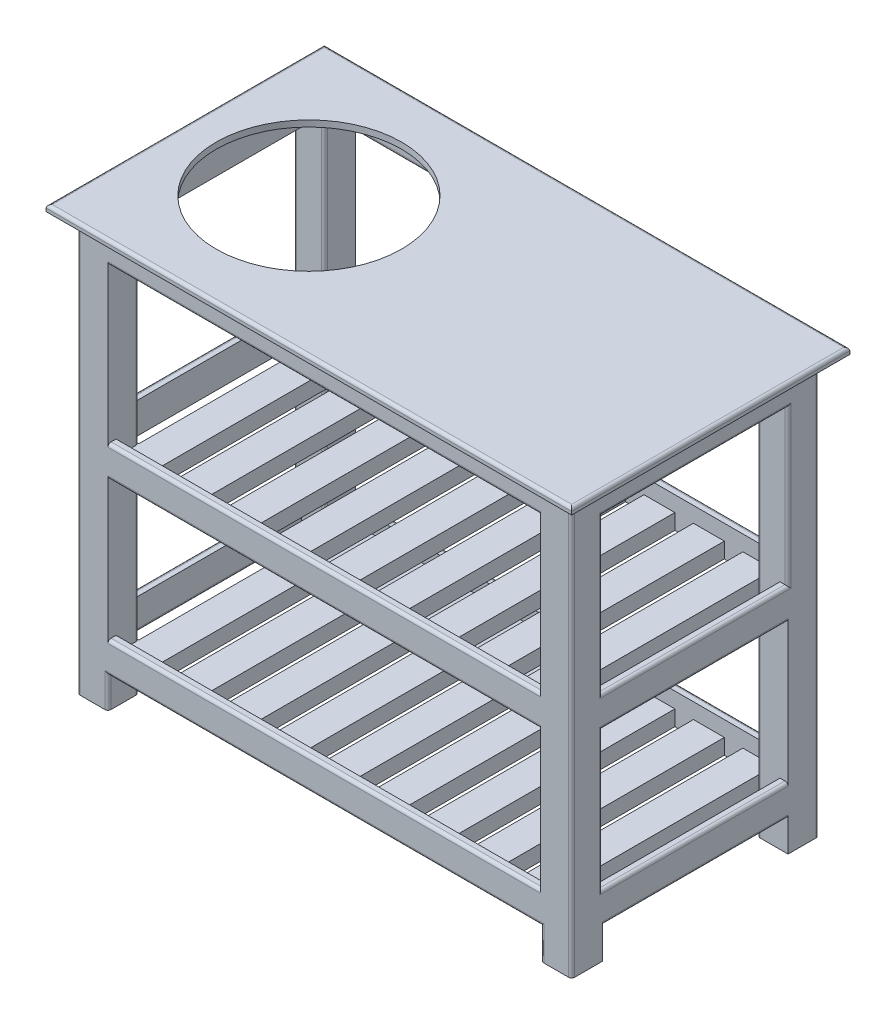
from build123d import *

# Parameters (mm, degrees)
SKETCH1_W           = 850
SKETCH1_H           = 450
BOSS_EXTRUDE1_DEPTH = 10
SKETCH2_W           = 50
SKETCH2_H           = 50
BOSS_EXTRUDE2_DEPTH = 675
BOSS_EXTRUDE3_REACH = 777
SKETCH3_W           = 13
SKETCH3_H           = 50
BOSS_EXTRUDE4_REACH = 377
SKETCH4_W           = 13
SKETCH4_H           = 50
SKETCH5_W           = 50
SKETCH5_H           = 25
BOSS_EXTRUDE5_DEPTH = 374
SKETCH6_W           = 50
SKETCH6_H           = 25
BOSS_EXTRUDE6_DEPTH = 374
LPATTERN2_COUNT     = 9
LPATTERN2_PITCH     = 80
LPATTERN3_COUNT     = 9
LPATTERN3_PITCH     = 80
CUT_EXTRUDE1_REACH  = 687
SKETCH7_R           = 150
FILLET2_R           = 5
FILLET3_R           = 5


with BuildPart() as part:
    # Sketch1 → Boss-Extrude1 (new body)
    with BuildSketch(Plane(origin=(0, 0, 0), x_dir=(1, 0, 0), z_dir=(0, 1, 0))):
        Rectangle(SKETCH1_W, SKETCH1_H)
    extrude(amount=BOSS_EXTRUDE1_DEPTH)

    # Sketch2 → Boss-Extrude2 (add)
    with BuildSketch(Plane.XZ):
        with Locations((-375, -175)):
            Rectangle(SKETCH2_W, SKETCH2_H)
        with Locations((-375, 175)):
            Rectangle(SKETCH2_W, SKETCH2_H)
        with Locations((375, 175)):
            Rectangle(SKETCH2_W, SKETCH2_H)
        with Locations((375, -175)):
            Rectangle(SKETCH2_W, SKETCH2_H)
    extrude(amount=BOSS_EXTRUDE2_DEPTH)

    # Sketch3 → Boss-Extrude3 (add, up to next)
    with BuildSketch(Plane(origin=(-350, 0, 0), x_dir=(0, 0, -1), z_dir=(1, 0, 0)), mode=Mode.PRIVATE) as boss_extrude3_sk1:
        with Locations((193.5, -600)):
            Rectangle(SKETCH3_W, SKETCH3_H)
    boss_extrude3_tool1 = extrude(boss_extrude3_sk1.sketch, amount=BOSS_EXTRUDE3_REACH, mode=Mode.PRIVATE) - part.part
    add(boss_extrude3_tool1.solids().sort_by_distance((-350, -600, -193.5))[0])
    # Sketch3 → Boss-Extrude3 (add, up to next)
    with BuildSketch(Plane(origin=(-350, 0, 0), x_dir=(0, 0, -1), z_dir=(1, 0, 0)), mode=Mode.PRIVATE) as boss_extrude3_sk2:
        with Locations((193.5, -325)):
            Rectangle(SKETCH3_W, SKETCH3_H)
    boss_extrude3_tool2 = extrude(boss_extrude3_sk2.sketch, amount=BOSS_EXTRUDE3_REACH, mode=Mode.PRIVATE) - part.part
    add(boss_extrude3_tool2.solids().sort_by_distance((-350, -325, -193.5))[0])
    # Sketch3 → Boss-Extrude3 (add, up to next)
    with BuildSketch(Plane(origin=(-350, 0, 0), x_dir=(0, 0, -1), z_dir=(1, 0, 0)), mode=Mode.PRIVATE) as boss_extrude3_sk3:
        with Locations((193.5, -25)):
            Rectangle(SKETCH3_W, SKETCH3_H)
    boss_extrude3_tool3 = extrude(boss_extrude3_sk3.sketch, amount=BOSS_EXTRUDE3_REACH, mode=Mode.PRIVATE) - part.part
    add(boss_extrude3_tool3.solids().sort_by_distance((-350, -25, -193.5))[0])

    # Mirror1: part across plane


with BuildPart() as part_1:
    add(part.part)
    add(part.part.mirror(Plane.XY))

    # Sketch4 → Boss-Extrude4 (add, up to next)
    with BuildSketch(Plane.XY.offset(-150), mode=Mode.PRIVATE) as boss_extrude4_sk1:
        with Locations((393.5, -600)):
            Rectangle(SKETCH4_W, SKETCH4_H)
    boss_extrude4_tool1 = extrude(boss_extrude4_sk1.sketch, amount=BOSS_EXTRUDE4_REACH, mode=Mode.PRIVATE) - part_1.part
    add(boss_extrude4_tool1.solids().sort_by_distance((393.5, -600, -150))[0])
    # Sketch4 → Boss-Extrude4 (add, up to next)
    with BuildSketch(Plane.XY.offset(-150), mode=Mode.PRIVATE) as boss_extrude4_sk2:
        with Locations((393.5, -325)):
            Rectangle(SKETCH4_W, SKETCH4_H)
    boss_extrude4_tool2 = extrude(boss_extrude4_sk2.sketch, amount=BOSS_EXTRUDE4_REACH, mode=Mode.PRIVATE) - part_1.part
    add(boss_extrude4_tool2.solids().sort_by_distance((393.5, -325, -150))[0])
    # Sketch4 → Boss-Extrude4 (add, up to next)
    with BuildSketch(Plane.XY.offset(-150), mode=Mode.PRIVATE) as boss_extrude4_sk3:
        with Locations((393.5, -25)):
            Rectangle(SKETCH4_W, SKETCH4_H)
    boss_extrude4_tool3 = extrude(boss_extrude4_sk3.sketch, amount=BOSS_EXTRUDE4_REACH, mode=Mode.PRIVATE) - part_1.part
    add(boss_extrude4_tool3.solids().sort_by_distance((393.5, -25, -150))[0])

    # Mirror2: part across plane


with BuildPart() as part_2:
    add(part_1.part)
    add(part_1.part.mirror(Plane(origin=(0, 0, 0), x_dir=(0, 0, 1), z_dir=(1, 0, 0))))

    # Sketch5 → Boss-Extrude5 (add)
    with BuildSketch(Plane.XY.offset(-187)):
        with Locations((-325, -337.5)):
            Rectangle(SKETCH5_W, SKETCH5_H)
    boss_extrude5 = extrude(amount=BOSS_EXTRUDE5_DEPTH)

    # Sketch6 → Boss-Extrude6 (add)
    with BuildSketch(Plane.XY.offset(-187)):
        with Locations((-325, -612.5)):
            Rectangle(SKETCH6_W, SKETCH6_H)
    boss_extrude6 = extrude(amount=BOSS_EXTRUDE6_DEPTH)

    # LPattern2: Boss-Extrude5 ×9
    with Locations(*[(i * LPATTERN2_PITCH, 0, 0) for i in range(1, LPATTERN2_COUNT)]):
        add(boss_extrude5)

    # LPattern3: Boss-Extrude6 ×9
    with Locations(*[(i * LPATTERN3_PITCH, 0, 0) for i in range(1, LPATTERN3_COUNT)]):
        add(boss_extrude6)

    # Sketch7 → Cut-Extrude1 (cut, up to next)
    with BuildSketch(Plane(origin=(0, 10, 0), x_dir=(1, 0, 0), z_dir=(0, 1, 0)), mode=Mode.PRIVATE) as cut_extrude1_sk1:
        with Locations((-225, 0)):
            Circle(SKETCH7_R)
    cut_extrude1_tool1 = extrude(cut_extrude1_sk1.sketch, amount=-CUT_EXTRUDE1_REACH, mode=Mode.PRIVATE) & part_2.part
    add(cut_extrude1_tool1.solids().sort_by_distance((-225, 10, 0))[0], mode=Mode.SUBTRACT)

    # Fillet2
    fillet2_edges = [part_2.edges().sort_by_distance(p)[0] for p in [
        (-400, -337.5, 200),
        (-350, -650, 200),
        (0, -625, 200),
        (350, -650, 200),
        (400, -337.5, 200),
        (0, -50, 200),
        (0, -300, 200),
        (0, -350, 200),
        (0, -575, 200),
        (-400, -175, -150),
        (-400, -300, 0),
        (-400, -175, 150),
        (-400, -50, 0),
        (-400, -462.5, -150),
        (-400, -575, 0),
        (-400, -462.5, 150),
        (-400, -350, 0),
        (-400, -650, -150),
        (-400, -337.5, -200),
        (400, -337.5, -200),
        (0, -625, -200),
        (0, -575, -200),
        (350, -462.5, -200),
        (0, -350, -200),
        (0, -300, -200),
        (400, -625, 0),
        (400, -462.5, 150),
        (400, -575, 0),
        (400, -350, 0),
        (400, -175, 150),
        (400, -300, 0),
        (400, -175, -150),
        (400, -50, 0),
        (-350, -650, 150),
        (350, -337.5, 150),
        (-350, -162.5, 150),
        (-350, -475, 150),
        (-350, -162.5, -150),
        (-350, -475, -150),
        (-350, -650, -150),
        (-387, -625, 0),
        (350, -337.5, -150),
        (0, -50, -187),
    ]]
    fillet(fillet2_edges, radius=FILLET2_R)

    # Fillet3
    fillet3_edges = [part_2.edges().sort_by_distance(p)[0] for p in [
        (-425, 10, 0),
        (0, 10, 225),
        (425, 10, 0),
        (0, 10, -225),
    ]]
    fillet(fillet3_edges, radius=FILLET3_R)


solid = part_2.part
